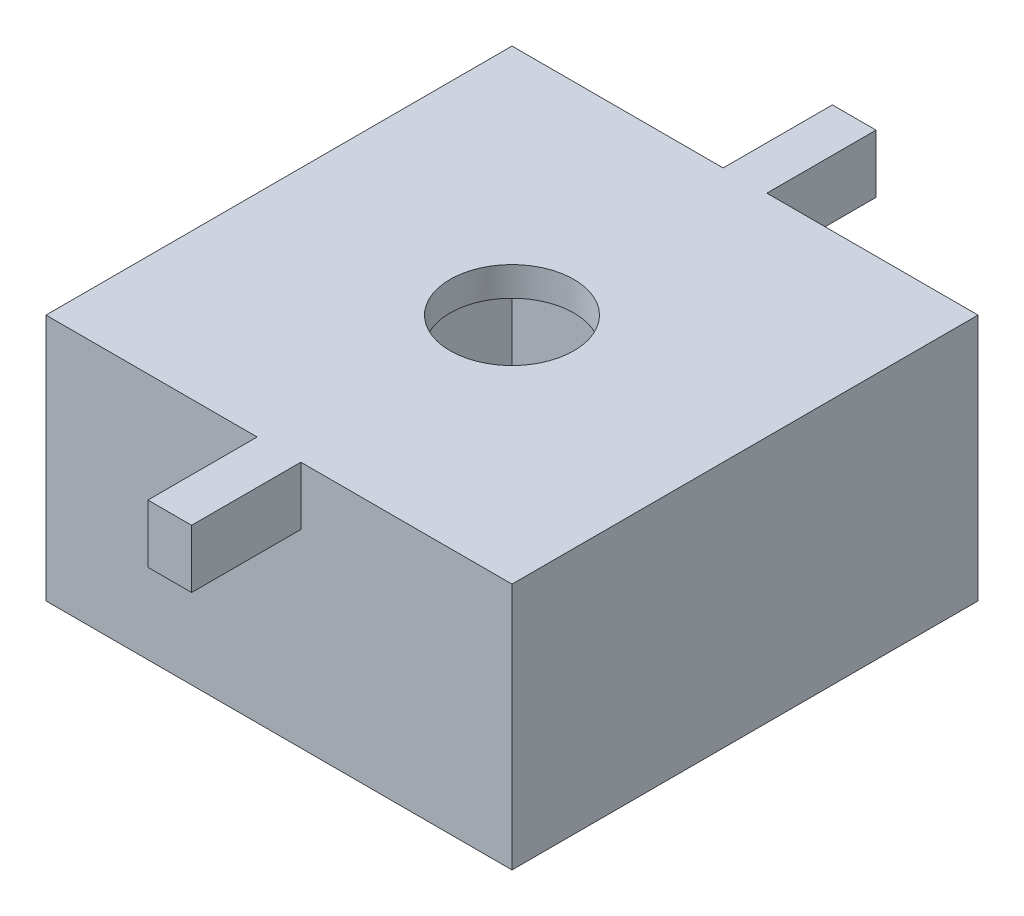
from build123d import *

# Parameters (mm, degrees)
SKETCH1_W           = 32
SKETCH1_H           = 32
SKETCH1_W_2         = 28
SKETCH1_H_2         = 28
BOSS_EXTRUDE1_DEPTH = 15
SKETCH2_W           = 32
SKETCH2_H           = 32
BOSS_EXTRUDE2_DEPTH = 2
CUT_EXTRUDE1_REACH  = 19
SKETCH3_R           = 4.25
SKETCH5_W           = 3
SKETCH5_H           = 4
BOSS_EXTRUDE3_DEPTH = 7.5


with BuildPart() as part:
    # Sketch1 → Boss-Extrude1 (new body)
    with BuildSketch(Plane(origin=(0, 0, 0), x_dir=(1, 0, 0), z_dir=(0, 1, 0))):
        Rectangle(SKETCH1_W, SKETCH1_H)
        Rectangle(SKETCH1_W_2, SKETCH1_H_2, mode=Mode.SUBTRACT)
    extrude(amount=BOSS_EXTRUDE1_DEPTH)

    # Sketch2 → Boss-Extrude2 (add)
    with BuildSketch(Plane(origin=(0, 15, 0), x_dir=(1, 0, 0), z_dir=(0, 1, 0))):
        Rectangle(SKETCH2_W, SKETCH2_H)
    extrude(amount=BOSS_EXTRUDE2_DEPTH)

    # Sketch3 → Cut-Extrude1 (cut, up to next)
    with BuildSketch(Plane(origin=(0, 17, 0), x_dir=(1, 0, 0), z_dir=(0, 1, 0)), mode=Mode.PRIVATE) as cut_extrude1_sk1:
        Circle(SKETCH3_R)
    cut_extrude1_tool1 = extrude(cut_extrude1_sk1.sketch, amount=-CUT_EXTRUDE1_REACH, mode=Mode.PRIVATE) & part.part
    add(cut_extrude1_tool1.solids().sort_by_distance((0, 17, 0))[0], mode=Mode.SUBTRACT)

    # Sketch5 → Boss-Extrude3 (add)
    with BuildSketch(Plane(origin=(0, 0, -16), x_dir=(-1, 0, 0), z_dir=(0, 0, -1))):
        with Locations((0, 15)):
            Rectangle(SKETCH5_W, SKETCH5_H)
    boss_extrude3 = extrude(amount=BOSS_EXTRUDE3_DEPTH)

    # Mirror1: Boss-Extrude3 across plane
    add(boss_extrude3.mirror(Plane.XY))


solid = part.part
